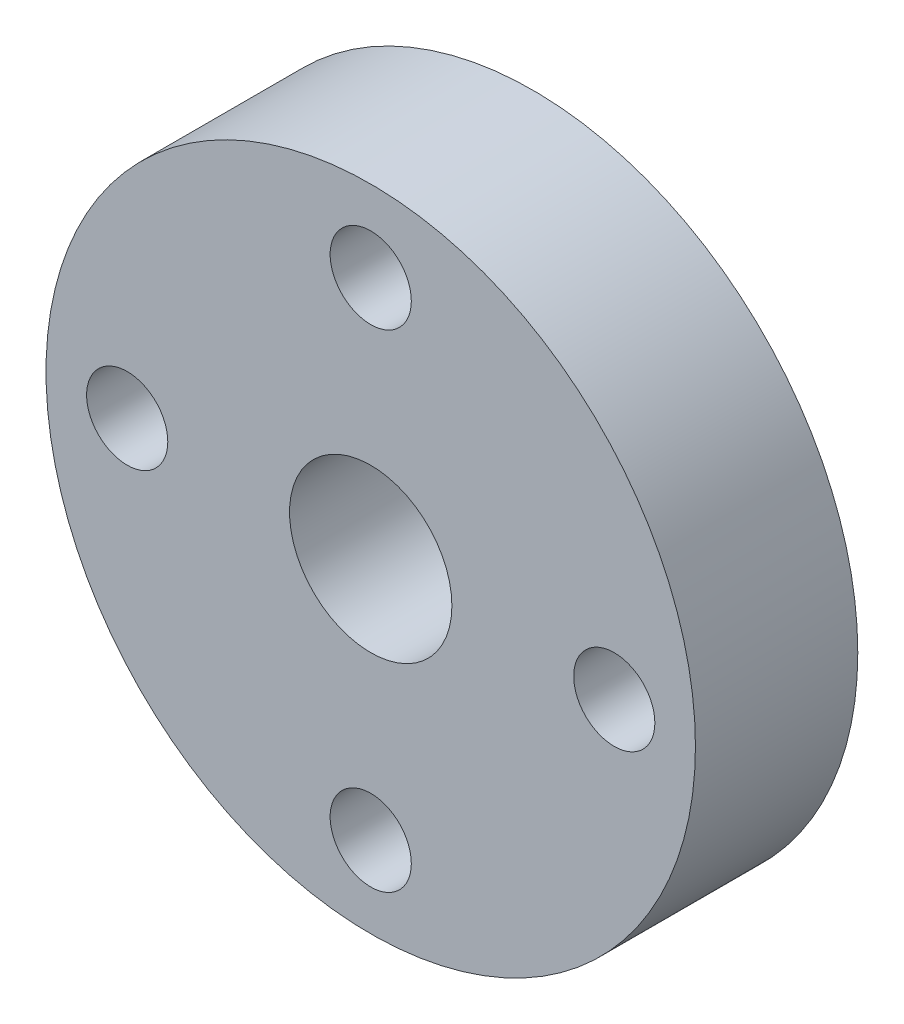
from build123d import *

# Parameters (mm, degrees)
SKETCH1_R           = 20
SKETCH1_R_2         = 5
SKETCH1_R_3         = 2.5
BOSS_EXTRUDE1_DEPTH = 10


with BuildPart() as part:
    # Sketch1 → Boss-Extrude1 (new body)
    with BuildSketch(Plane.XY):
        Circle(SKETCH1_R)
        Circle(SKETCH1_R_2, mode=Mode.SUBTRACT)
        with Locations((0, 15)):
            Circle(SKETCH1_R_3, mode=Mode.SUBTRACT)
        with Locations((15, 0)):
            Circle(SKETCH1_R_3, mode=Mode.SUBTRACT)
        with Locations((0, -15)):
            Circle(SKETCH1_R_3, mode=Mode.SUBTRACT)
        with Locations((-15, 0)):
            Circle(SKETCH1_R_3, mode=Mode.SUBTRACT)
    extrude(amount=BOSS_EXTRUDE1_DEPTH)


solid = part.part
